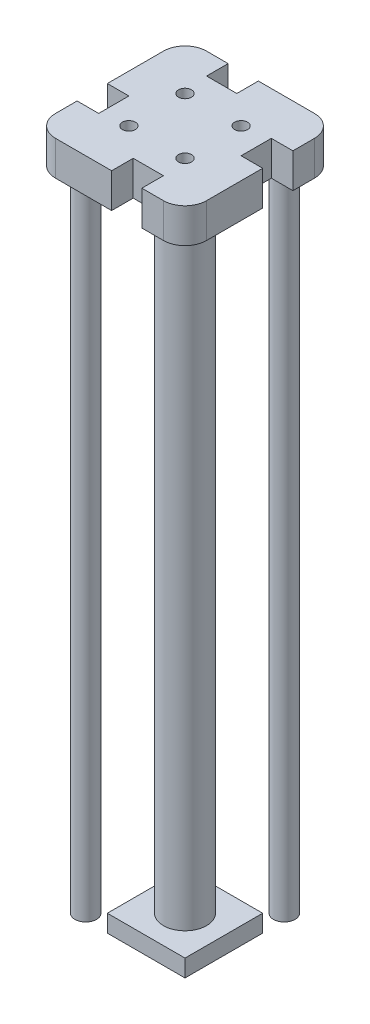
from build123d import *

# Parameters (mm, degrees)
SKETCH1_W           = 35
SKETCH1_H           = 35
BOSS_EXTRUDE1_DEPTH = 8
SKETCH2_W           = 7
SKETCH2_H           = 5
SKETCH2_W_2         = 5
SKETCH2_H_2         = 7
SKETCH2_R           = 1.5
CUT_EXTRUDE1_DEPTH  = 51.139804547
SKETCH2_5_R         = 4
SKETCH2_5_R_2       = 1.5
CUT_EXTRUDE2_DEPTH  = 4
SKETCH2_7_R         = 2.5
SKETCH2_7_R_2       = 5
BOSS_EXTRUDE2_DEPTH = 150
SKETCH3_W           = 18
SKETCH3_H           = 18
BOSS_EXTRUDE3_DEPTH = 4
FILLET1_R           = 5


with BuildPart() as part:
    # Sketch1 → Boss-Extrude1 (new body)
    with BuildSketch(Plane(origin=(0, 0, 0), x_dir=(1, 0, 0), z_dir=(0, 1, 0))):
        with Locations((17.5, 17.5)):
            Rectangle(SKETCH1_W, SKETCH1_H)
    extrude(amount=BOSS_EXTRUDE1_DEPTH)

    # Sketch2 → Cut-Extrude1 (cut, through all)
    with BuildSketch(Plane.XZ):
        with Locations((21.5, -2.5)):
            Rectangle(SKETCH2_W, SKETCH2_H)
        with Locations((2.5, -13.5)):
            Rectangle(SKETCH2_W_2, SKETCH2_H_2)
        with Locations((32.5, -21.5)):
            Rectangle(SKETCH2_W_2, SKETCH2_H_2)
        with Locations((13.5, -32.5)):
            Rectangle(SKETCH2_W, SKETCH2_H)
        with Locations((11, -11)):
            Circle(SKETCH2_R)
        with Locations((24, -11)):
            Circle(SKETCH2_R)
        with Locations((24, -24)):
            Circle(SKETCH2_R)
        with Locations((11, -24)):
            Circle(SKETCH2_R)
    extrude(amount=-CUT_EXTRUDE1_DEPTH, mode=Mode.SUBTRACT)

    # Sketch2_5 → Cut-Extrude2 (cut)
    with BuildSketch(Plane.XZ):
        with Locations((29, -6)):
            Circle(SKETCH2_5_R)
        with Locations((6, -29)):
            Circle(SKETCH2_5_R)
        with Locations((11, -11)):
            Circle(SKETCH2_5_R_2)
    extrude(amount=-CUT_EXTRUDE2_DEPTH, mode=Mode.SUBTRACT)

    # Sketch2_7 → Boss-Extrude2 (add)
    with BuildSketch(Plane.XZ):
        with Locations((6, -6)):
            Circle(SKETCH2_7_R)
        with Locations((29, -29)):
            Circle(SKETCH2_7_R)
        with Locations((17.5, -17.5)):
            Circle(SKETCH2_7_R_2)
    extrude(amount=BOSS_EXTRUDE2_DEPTH)

    # Sketch3 → Boss-Extrude3 (add)
    with BuildSketch(Plane(origin=(0, -150, 0), x_dir=(-1, 0, 0), z_dir=(0, -1, 0))):
        with Locations((-17.5, 17.5)):
            Rectangle(SKETCH3_W, SKETCH3_H)
    extrude(amount=BOSS_EXTRUDE3_DEPTH)

    # Fillet1
    fillet1_edges = [part.edges().sort_by_distance(p)[0] for p in [
        (35, 4, -35),
        (0, 4, -35),
        (0, 4, 0),
        (35, 4, 0),
    ]]
    fillet(fillet1_edges, radius=FILLET1_R)


solid = part.part
